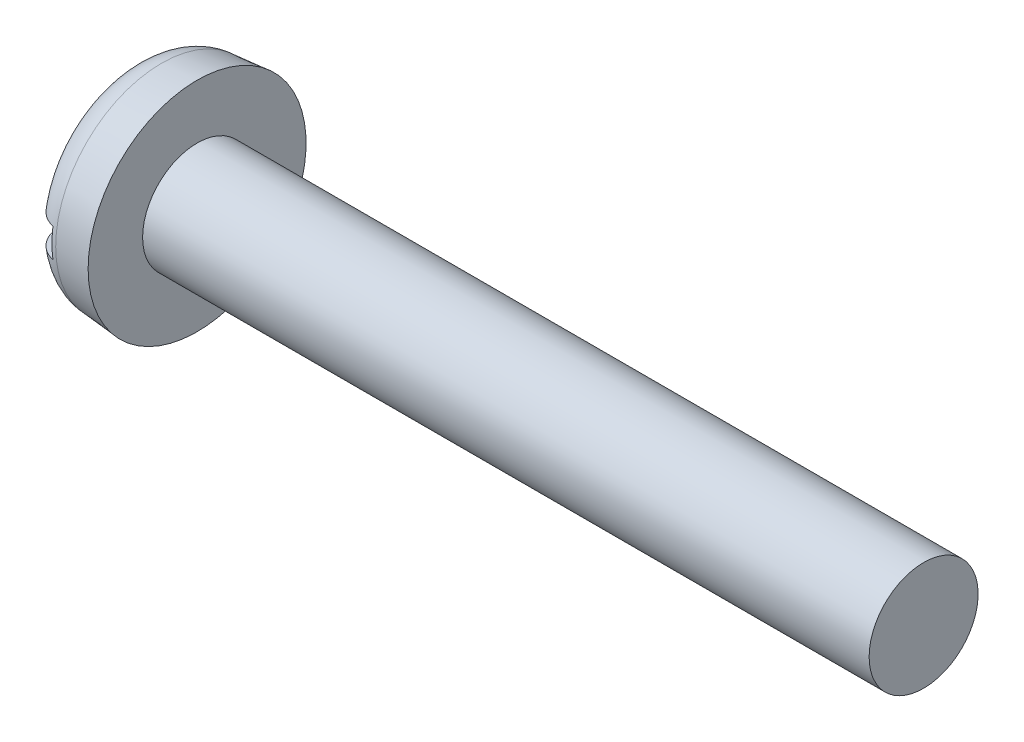
from build123d import *

# Parameters (mm, degrees)
FILLET2_R  = 1.8
SKETCH2_W  = 12
SKETCH2_H  = 1.6
SLOT_DEPTH = 1.4


with BuildPart() as part:
    # BodySke → Base-Revolve (revolve)
    with BuildSketch(Plane.XY):
        Polygon((3.6, 3), (3.6, 6), (0, 5.685040811), (0, 0), (43.6, 0), (43.6, 3), align=None)
    revolve(axis=Axis((-25.4, 0, 0), (1, 0, 0)))

    # Fillet2
    fillet2_edges = [part.edges().sort_by_distance(p)[0] for p in [
        (0, -5.685040811, 0),
    ]]
    fillet(fillet2_edges, radius=FILLET2_R)

    # Sketch2 → Slot (cut)
    with BuildSketch(Plane(origin=(0, 0, 0), x_dir=(0, 0, -1), z_dir=(1, 0, 0))):
        Rectangle(SKETCH2_W, SKETCH2_H)
    extrude(amount=SLOT_DEPTH, mode=Mode.SUBTRACT)


solid = part.part
